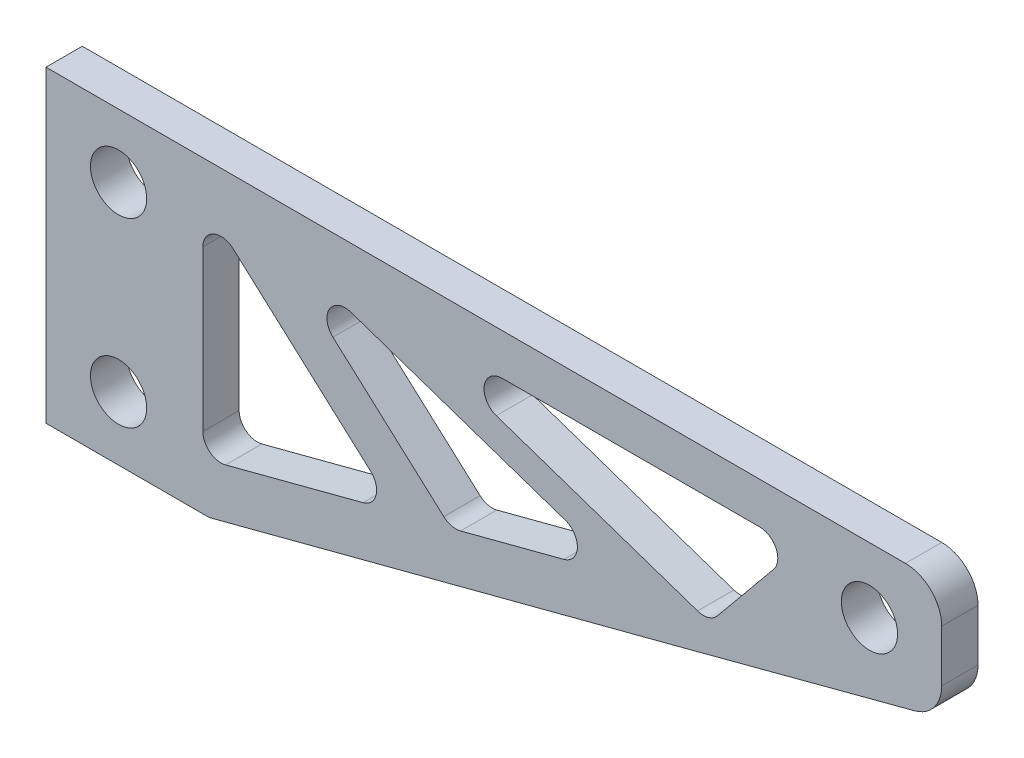
from build123d import *

# Parameters (mm, degrees)
SKETCH_1_R      = 1.55
EXTRUDE_1_DEPTH = 2


with BuildPart() as part:
    # 草图1 → 凸台-拉伸1 (new body)
    with BuildSketch(Plane.XY):
        with BuildLine():
            Line((-4.5, 10), (4.5, 10))
            Line((4.5, 10), (42.874156462, 10))
            ThreePointArc((42.874156462, 10), (44.288370024, 9.414213562), (44.874156462, 8))
            Line((44.874156462, 8), (44.874156462, 5.149651674))
            ThreePointArc((44.874156462, 5.149651674), (44.458733517, 3.929358448), (43.385040906, 3.216003028))
            Line((43.385040906, 3.216003028), (31.212777732, 0))
            Line((31.212777732, 0), (4.5, -7))
            Line((4.5, -7), (-4.5, -7))
            Line((-4.5, -7), (-4.5, 10))
        make_face()
        with Locations((-0.5, 6.5)):
            Circle(SKETCH_1_R, mode=Mode.SUBTRACT)
        with Locations((40.890589187, 6.411336053)):
            Circle(SKETCH_1_R, mode=Mode.SUBTRACT)
        with Locations((-0.5, -3.5)):
            Circle(SKETCH_1_R, mode=Mode.SUBTRACT)
        with BuildLine():
            Line((4.146506743, 5.745070559), (4.146506743, -3.06967977))
            ThreePointArc((4.146506743, -3.06967977), (4.535559953, -3.861351432), (5.399994782, -4.037018291))
            Line((5.399994782, -4.037018291), (12.9777079, -2.051302228))
            ThreePointArc((12.9777079, -2.051302228), (13.695890464, -1.320302954), (13.3936769, -0.341112934))
            Line((13.3936769, -0.341112934), (5.815963783, 6.487921333))
            ThreePointArc((5.815963783, 6.487921333), (4.739970791, 6.658705344), (4.146506743, 5.745070559))
        make_face(mode=Mode.SUBTRACT)
        with BuildLine():
            Line((11.315621432, 5.017151032), (17.427365311, -0.490751911))
            ThreePointArc((17.427365311, -0.490751911), (17.860483104, -0.71957174), (18.35031039, -0.715239658))
            Line((18.35031039, -0.715239658), (24.045702218, 0.777219988))
            ThreePointArc((24.045702218, 0.777219988), (24.791574656, 1.708800456), (24.11419002, 2.691306394))
            Line((24.11419002, 2.691306394), (12.307054312, 6.706749691))
            ThreePointArc((12.307054312, 6.706749691), (11.122598499, 6.266093001), (11.315621432, 5.017151032))
        make_face(mode=Mode.SUBTRACT)
        with BuildLine():
            Line((20.321587877, 5.773595304), (31.417514437, 2.000024386))
            ThreePointArc((31.417514437, 2.000024386), (32.013649619, 1.98508799), (32.512293671, 2.312126767))
            Line((32.512293671, 2.312126767), (35.611244636, 6.085697684))
            ThreePointArc((35.611244636, 6.085697684), (35.742500286, 7.147750779), (34.838441243, 7.720343189))
            Line((34.838441243, 7.720343189), (20.643563718, 7.720343189))
            ThreePointArc((20.643563718, 7.720343189), (19.656966565, 6.883518118), (20.321587877, 5.773595304))
        make_face(mode=Mode.SUBTRACT)
    extrude(amount=EXTRUDE_1_DEPTH)


solid = part.part
